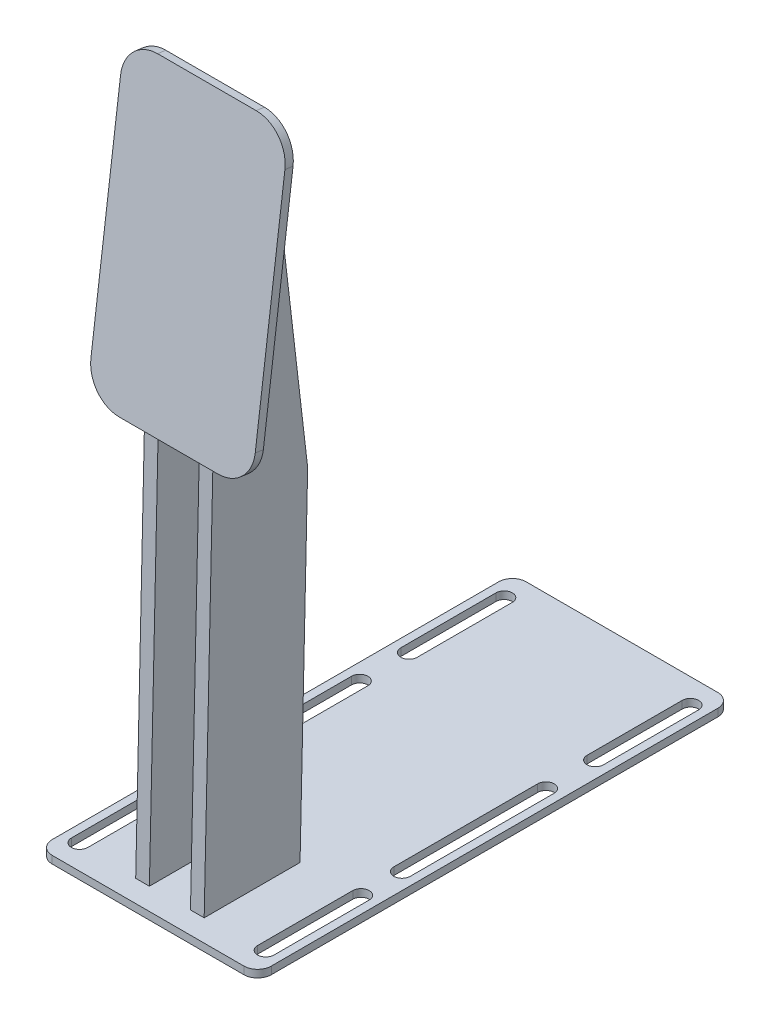
from build123d import *

# Parameters (mm, degrees)
SKETCH1_R           = 7.112045721
BOSS_EXTRUDE1_DEPTH = 2.75
BOSS_EXTRUDE2_DEPTH = 3
BOSS_EXTRUDE3_DEPTH = 2.5


with BuildPart() as part:
    # Sketch1 → Boss-Extrude1 (new body)
    with BuildSketch(Plane(origin=(0, 0, 0), x_dir=(1, 0, 0), z_dir=(0, 1, 0))):
        with BuildLine():
            Line((-35, 86.51875), (35, 86.51875))
            ThreePointArc((35, 86.51875), (38.535533906, 85.054283906), (40, 81.51875))
            Line((40, 81.51875), (40, -81.51875))
            ThreePointArc((40, -81.51875), (38.535533906, -85.054283906), (35, -86.51875))
            Line((35, -86.51875), (-35, -86.51875))
            ThreePointArc((-35, -86.51875), (-38.535533906, -85.054283906), (-40, -81.51875))
            Line((-40, -81.51875), (-40, 81.51875))
            ThreePointArc((-40, 81.51875), (-38.535533906, 85.054283906), (-35, 86.51875))
        make_face()
        with Locations((0, -48.920084539)):
            Circle(SKETCH1_R, mode=Mode.SUBTRACT)
        with BuildLine():
            Line((37, 77.51875), (37, 42.76875))
            ThreePointArc((37, 42.76875), (34, 39.76875), (31, 42.76875))
            Line((31, 42.76875), (31, 77.51875))
            ThreePointArc((31, 77.51875), (34, 80.51875), (37, 77.51875))
        make_face(mode=Mode.SUBTRACT)
        with BuildLine():
            Line((-37, 77.51875), (-37, 42.76875))
            ThreePointArc((-37, 42.76875), (-34, 39.76875), (-31, 42.76875))
            Line((-31, 42.76875), (-31, 77.51875))
            ThreePointArc((-31, 77.51875), (-34, 80.51875), (-37, 77.51875))
        make_face(mode=Mode.SUBTRACT)
        with BuildLine():
            Line((37, -77.51875), (37, -42.76875))
            ThreePointArc((37, -42.76875), (34, -39.76875), (31, -42.76875))
            Line((31, -42.76875), (31, -77.51875))
            ThreePointArc((31, -77.51875), (34, -80.51875), (37, -77.51875))
        make_face(mode=Mode.SUBTRACT)
        with BuildLine():
            Line((-37, -77.51875), (-37, -42.76875))
            ThreePointArc((-37, -42.76875), (-34, -39.76875), (-31, -42.76875))
            Line((-31, -42.76875), (-31, -77.51875))
            ThreePointArc((-31, -77.51875), (-34, -80.51875), (-37, -77.51875))
        make_face(mode=Mode.SUBTRACT)
        with BuildLine():
            Line((37, 24.76875), (37, -27.76875))
            ThreePointArc((37, -27.76875), (34, -30.76875), (31, -27.76875))
            Line((31, -27.76875), (31, 24.76875))
            ThreePointArc((31, 24.76875), (34, 27.76875), (37, 24.76875))
        make_face(mode=Mode.SUBTRACT)
        with BuildLine():
            Line((-37, 24.76875), (-37, -27.76875))
            ThreePointArc((-37, -27.76875), (-34, -30.76875), (-31, -27.76875))
            Line((-31, -27.76875), (-31, 24.76875))
            ThreePointArc((-31, 24.76875), (-34, 27.76875), (-37, 24.76875))
        make_face(mode=Mode.SUBTRACT)
    extrude(amount=BOSS_EXTRUDE1_DEPTH)


with BuildPart() as body_2:
    # Sketch3 → Boss-Extrude2 (new body)
    with BuildSketch(Plane(origin=(0, 12.370657811, 96.117341263), x_dir=(0, -0.991819174, 0.127650801), z_dir=(0, 0.127650801, 0.991819174))):
        with BuildLine():
            Line((-231.622374558, 30), (-146.731557682, 30))
            ThreePointArc((-146.731557682, 30), (-138.246276308, 26.485281374), (-134.731557682, 18))
            Line((-134.731557682, 18), (-134.731557682, -18))
            ThreePointArc((-134.731557682, -18), (-138.246276308, -26.485281374), (-146.731557682, -30))
            Line((-146.731557682, -30), (-231.622374558, -30))
            ThreePointArc((-231.622374558, -30), (-240.107655932, -26.485281374), (-243.622374558, -18))
            Line((-243.622374558, -18), (-243.622374558, 18))
            ThreePointArc((-243.622374558, 18), (-240.107655932, 26.485281374), (-231.622374558, 30))
        make_face()
    extrude(amount=-BOSS_EXTRUDE2_DEPTH)

    # Sketch4 → Boss-Extrude3 (add, symmetric)
    with BuildSketch(Plane(origin=(10, 0, 0), x_dir=(0, 0, -1), z_dir=(1, 0, 0))):
        Polygon((-75.177387673, 151.567962638), (-78.530764988, 2.75), (-43.521880404, 2.75), (-40.738309922, 126.280771894), (-54.39829674, 243.088956939), (-63.39829674, 243.088956939), align=None)
    boss_extrude3 = extrude(amount=BOSS_EXTRUDE3_DEPTH, both=True)

    # Mirror2: Boss-Extrude3 across plane
    add(boss_extrude3.mirror(Plane(origin=(0, 0, 0), x_dir=(0, 0, 1), z_dir=(1, 0, 0))))


solid = Compound([part.part, body_2.part])
